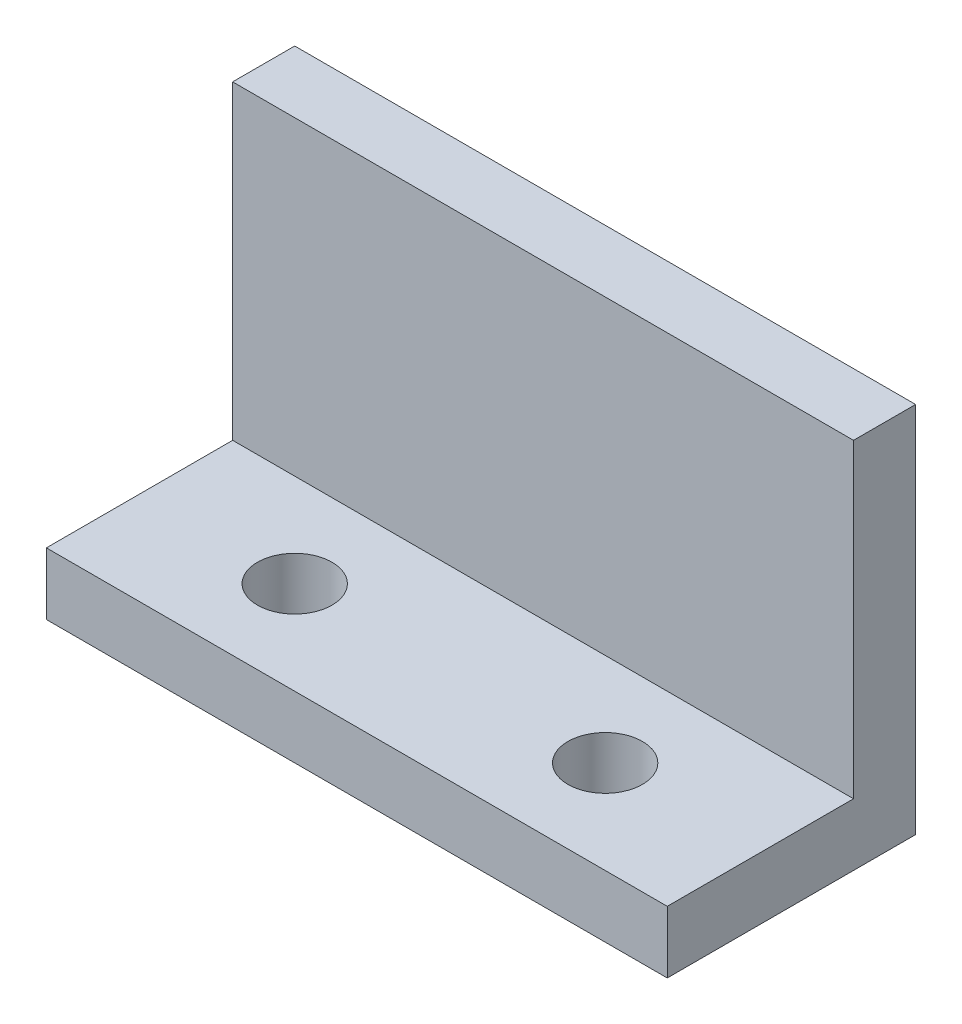
from build123d import *

# Parameters (mm, degrees)
SZKIC1_W                    = 100
SZKIC1_H                    = 60
DODANIE_WYCI_GNI_CIE1_DEPTH = 10
SZKIC2_W                    = 100
SZKIC2_H                    = 10
DODANIE_WYCI_GNI_CIE2_DEPTH = 30
OTW_R_POD_RUB_M101_D        = 12
SZYK_LINIOWY2_COUNT         = 2
SZYK_LINIOWY2_PITCH         = 50


with BuildPart() as part:
    # Szkic1 → Dodanie-wyciągnięcie1 (new body)
    with BuildSketch(Plane.XY):
        Rectangle(SZKIC1_W, SZKIC1_H)
    extrude(amount=DODANIE_WYCI_GNI_CIE1_DEPTH)

    # Szkic2 → Dodanie-wyciągnięcie2 (add)
    with BuildSketch(Plane.XY.offset(10)):
        with Locations((0, -25)):
            Rectangle(SZKIC2_W, SZKIC2_H)
    extrude(amount=DODANIE_WYCI_GNI_CIE2_DEPTH)

    # Otwór pod śrubę M101 (through all)
    with Locations(Plane(origin=(0, -20, 0), x_dir=(1, 0, 0), z_dir=(0, 1, 0))):
        with Locations((-25, -25)):
            otw_r_pod_rub_m101 = Hole(OTW_R_POD_RUB_M101_D / 2)

    # Szyk liniowy2: Otwór pod śrubę M101 ×2
    with Locations(*[(i * SZYK_LINIOWY2_PITCH, 0, 0) for i in range(1, SZYK_LINIOWY2_COUNT)]):
        add(otw_r_pod_rub_m101, mode=Mode.SUBTRACT)


solid = part.part
